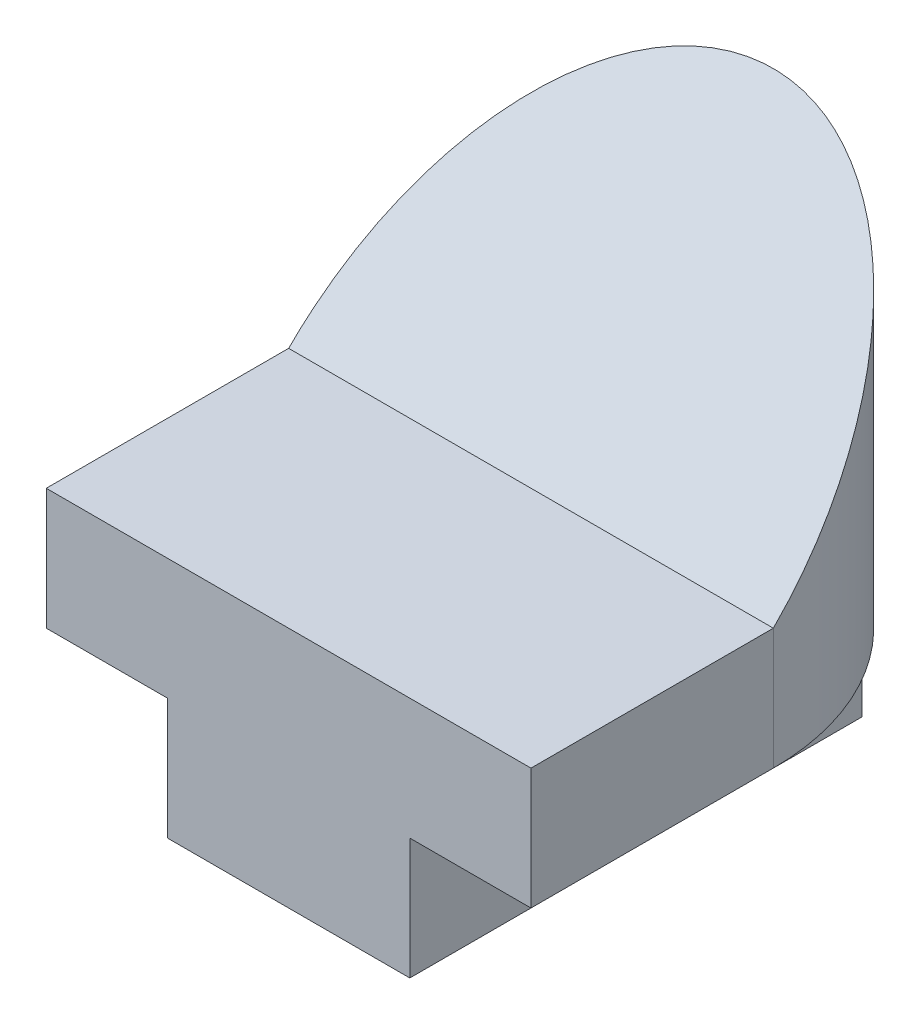
from build123d import *

# Parameters (mm, degrees)
SKETCH1_W           = 40
SKETCH1_H           = 40
BOSS_EXTRUDE1_DEPTH = 40
SKETCH2_W           = 10
SKETCH2_H           = 10
CUT_EXTRUDE1_DEPTH  = 40
CUT_EXTRUDE2_DEPTH  = 40
CUT_EXTRUDE3_DEPTH  = 40
CUT_EXTRUDE4_DEPTH  = 40


with BuildPart() as part:
    # Sketch1 → Boss-Extrude1 (new body)
    with BuildSketch(Plane.XY):
        with Locations((20, 20)):
            Rectangle(SKETCH1_W, SKETCH1_H)
    extrude(amount=BOSS_EXTRUDE1_DEPTH)

    # Sketch2 → Cut-Extrude1 (cut)
    with BuildSketch(Plane.XY.offset(40)):
        with Locations((5, 5)):
            Rectangle(SKETCH2_W, SKETCH2_H)
        with Locations((35, 5)):
            Rectangle(SKETCH2_W, SKETCH2_H)
    extrude(amount=-CUT_EXTRUDE1_DEPTH, mode=Mode.SUBTRACT)

    # Sketch3 → Cut-Extrude2 (cut)
    with BuildSketch(Plane.XY.offset(40)):
        with BuildLine():
            Line((0, 40), (0, 20))
            ThreePointArc((0, 20), (5.857864376, 34.142135624), (20, 40))
            Line((20, 40), (0, 40))
        make_face()
        with BuildLine():
            Line((40, 40), (20, 40))
            ThreePointArc((20, 40), (34.142135624, 34.142135624), (40, 20))
            Line((40, 20), (40, 40))
        make_face()
    extrude(amount=-CUT_EXTRUDE2_DEPTH, mode=Mode.SUBTRACT)

    # Sketch4 → Cut-Extrude3 (cut)
    with BuildSketch(Plane(origin=(0, 0, 0), x_dir=(1, 0, 0), z_dir=(0, 1, 0))):
        with BuildLine():
            Line((0, 0), (0, -20))
            ThreePointArc((0, -20), (5.857864376, -5.857864376), (20, 0))
            Line((20, 0), (0, 0))
        make_face()
        with BuildLine():
            Line((40, 0), (20, 0))
            ThreePointArc((20, 0), (34.142135624, -5.857864376), (40, -20))
            Line((40, -20), (40, 0))
        make_face()
    extrude(amount=CUT_EXTRUDE3_DEPTH, mode=Mode.SUBTRACT)

    # Sketch5 → Cut-Extrude4 (cut)
    with BuildSketch(Plane(origin=(0, 0, 0), x_dir=(0, 0, -1), z_dir=(1, 0, 0))):
        Polygon((0, 40), (-20, 20), (-40, 20), (-40, 40), align=None)
    extrude(amount=CUT_EXTRUDE4_DEPTH, mode=Mode.SUBTRACT)


solid = part.part
